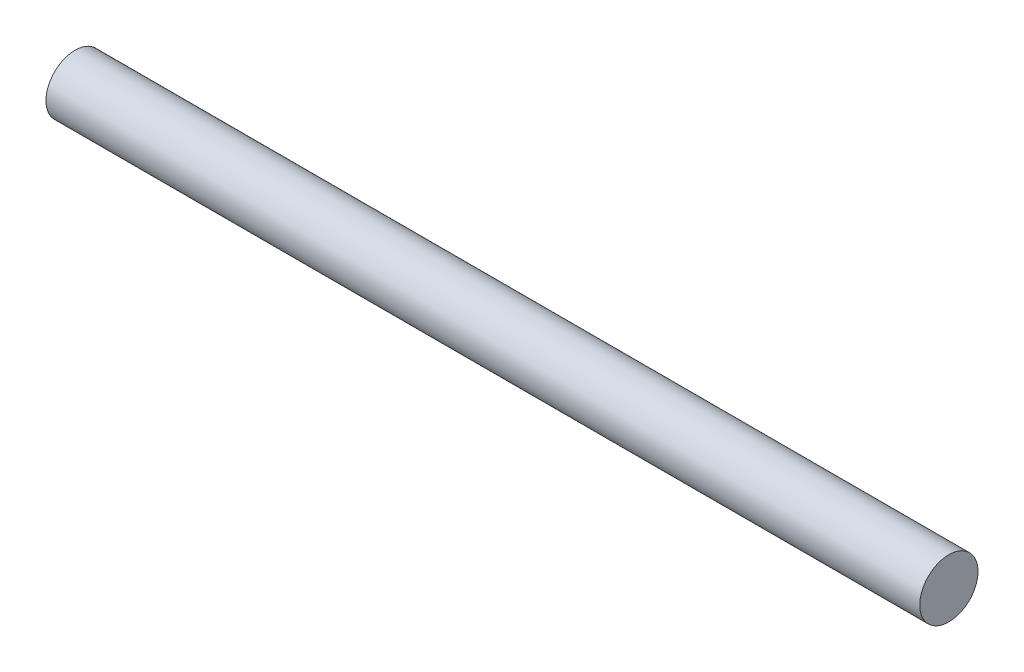
from build123d import *

# Parameters (mm, degrees)
SKETCH1_R           = 4
BOSS_EXTRUDE1_DEPTH = 120


with BuildPart() as part:
    # Sketch1 → Boss-Extrude1 (new body)
    with BuildSketch(Plane(origin=(0, 0, 0), x_dir=(0, 0, -1), z_dir=(1, 0, 0))):
        Circle(SKETCH1_R)
    extrude(amount=BOSS_EXTRUDE1_DEPTH)


solid = part.part
